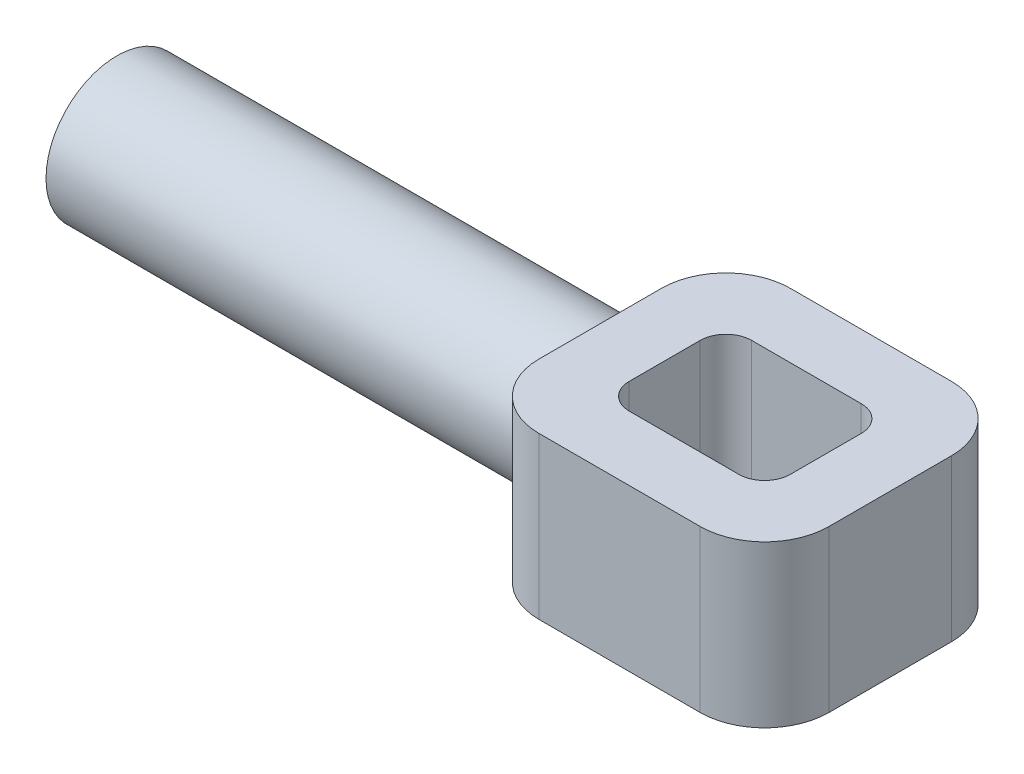
from build123d import *

# Parameters (mm, degrees)
SKETCH1_W           = 45
SKETCH1_H           = 39
SKETCH1_W_2         = 25
SKETCH1_H_2         = 19
EXTRUDE_THIN1_DEPTH = 25
FILLET1_R           = 10
FILLET2_R           = 4
SKETCH2_R           = 11
BOSS_EXTRUDE1_DEPTH = 75
SKETCH3_R           = 7.85
CUT_EXTRUDE1_DEPTH  = 30


with BuildPart() as part:
    # Sketch1 → Extrude-Thin1 (new body)
    with BuildSketch(Plane(origin=(0, 0, 0), x_dir=(1, 0, 0), z_dir=(0, 1, 0))):
        Rectangle(SKETCH1_W, SKETCH1_H)
        Rectangle(SKETCH1_W_2, SKETCH1_H_2, mode=Mode.SUBTRACT)
    extrude(amount=EXTRUDE_THIN1_DEPTH)

    # Fillet1
    fillet1_edges = [part.edges().sort_by_distance(p)[0] for p in [
        (22.5, 12.5, 19.5),
        (-22.5, 12.5, 19.5),
        (-22.5, 12.5, -19.5),
        (22.5, 12.5, -19.5),
    ]]
    fillet(fillet1_edges, radius=FILLET1_R)

    # Fillet2
    fillet2_edges = [part.edges().sort_by_distance(p)[0] for p in [
        (12.5, 12.5, 9.5),
        (12.5, 12.5, -9.5),
        (-12.5, 12.5, -9.5),
        (-12.5, 12.5, 9.5),
    ]]
    fillet(fillet2_edges, radius=FILLET2_R)

    # Sketch2 → Boss-Extrude1 (add)
    with BuildSketch(Plane(origin=(-22.5, 0, 3), x_dir=(0, 0, 1), z_dir=(-1, 0, 0))):
        with Locations((-3, 12.5)):
            Circle(SKETCH2_R)
    extrude(amount=BOSS_EXTRUDE1_DEPTH)

    # Sketch3 → Cut-Extrude1 (cut)
    with BuildSketch(Plane.ZY.offset(97.5)):
        with Locations((0, 12.5)):
            Circle(SKETCH3_R)
    extrude(amount=-CUT_EXTRUDE1_DEPTH, mode=Mode.SUBTRACT)


solid = part.part
